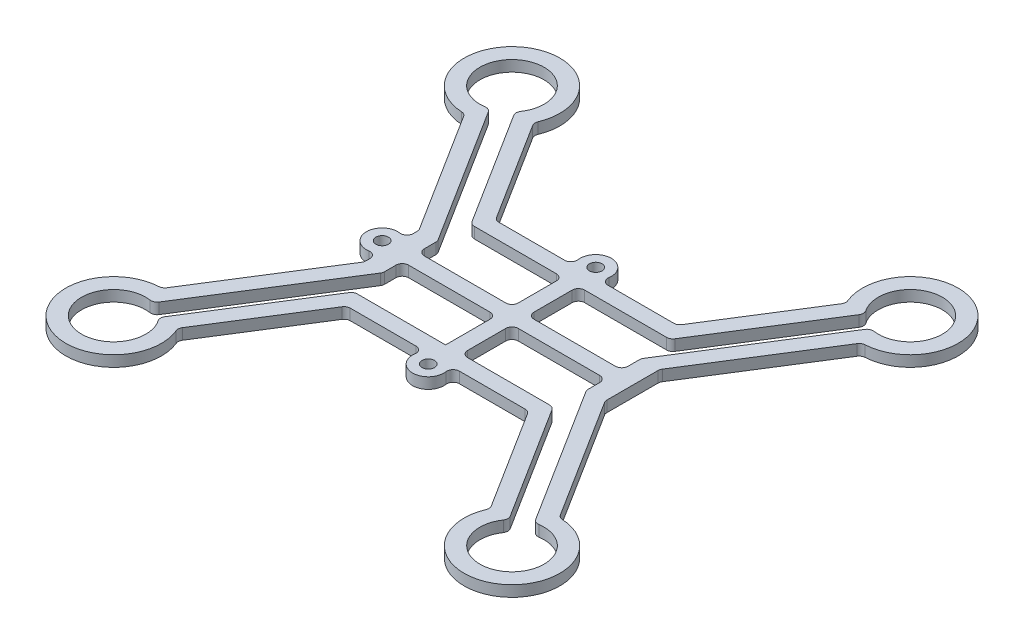
from build123d import *

# Parameters (mm, degrees)
SKETCH1_R           = 5.125
BOSS_EXTRUDE1_DEPTH = 1.75
CUT_EXTRUDE2_REACH  = 3.75
FILLET1_R           = 1
SKETCH4_R           = 2.5
SKETCH4_R_2         = 1
BOSS_EXTRUDE2_DEPTH = 1.75
FILLET2_R           = 1


with BuildPart() as part:
    # Sketch1 → Boss-Extrude1 (new body)
    with BuildSketch(Plane(origin=(0, 0, 0), x_dir=(1, 0, 0), z_dir=(0, 1, 0))):
        with BuildLine():
            Line((19.25, -4.372796114), (19.25, 4.372796114))
            Line((19.25, 4.372796114), (31.727014355, 24.170367928))
            ThreePointArc((31.727014355, 24.170367928), (35.898606592, 38.291735223), (24.95898291, 28.435781196))
            Line((24.95898291, 28.435781196), (14.52188958, 11.875))
            Line((14.52188958, 11.875), (-14.52188958, 11.875))
            Line((-14.52188958, 11.875), (-24.95898291, 28.435781196))
            ThreePointArc((-24.95898291, 28.435781196), (-35.898606592, 38.291735223), (-31.727014355, 24.170367928))
            Line((-31.727014355, 24.170367928), (-19.25, 4.372796114))
            Line((-19.25, 4.372796114), (-19.25, -4.372796114))
            Line((-19.25, -4.372796114), (-31.727014355, -24.170367928))
            ThreePointArc((-31.727014355, -24.170367928), (-35.898606592, -38.291735223), (-24.95898291, -28.435781196))
            Line((-24.95898291, -28.435781196), (-14.52188958, -11.875))
            Line((-14.52188958, -11.875), (14.52188958, -11.875))
            Line((14.52188958, -11.875), (24.95898291, -28.435781196))
            ThreePointArc((24.95898291, -28.435781196), (35.898606592, -38.291735223), (31.727014355, -24.170367928))
            Line((31.727014355, -24.170367928), (19.25, -4.372796114))
        make_face()
        with Locations((-31.819805153, 31.819805153)):
            Circle(SKETCH1_R, mode=Mode.SUBTRACT)
        with Locations((31.819805153, 31.819805153)):
            Circle(SKETCH1_R, mode=Mode.SUBTRACT)
        with Locations((-31.819805153, -31.819805153)):
            Circle(SKETCH1_R, mode=Mode.SUBTRACT)
        with Locations((31.819805153, -31.819805153)):
            Circle(SKETCH1_R, mode=Mode.SUBTRACT)
    extrude(amount=BOSS_EXTRUDE1_DEPTH)

    # Sketch2 → Cut-Extrude2 (cut, up to next)
    with BuildSketch(Plane(origin=(0, 1.75, 0), x_dir=(1, 0, 0), z_dir=(0, 1, 0)), mode=Mode.PRIVATE) as cut_extrude2_sk1:
        with BuildLine():
            ThreePointArc((-27.955034886, 28.453921053), (-29.087274778, 27.484035009), (-30.450746481, 26.88104991))
            Line((-30.450746481, 26.88104991), (-16.265380297, 4.372796114))
            Line((-16.265380297, 4.372796114), (-16.265380297, 1.2625))
            Line((-16.265380297, 1.2625), (-1.2625, 1.2625))
            Line((-1.2625, 1.2625), (-1.2625, 9.35))
            Line((-1.2625, 9.35), (-15.915179722, 9.35))
            Line((-15.915179722, 9.35), (-27.955034886, 28.453921053))
        make_face()
    cut_extrude2_tool1 = extrude(cut_extrude2_sk1.sketch, amount=-CUT_EXTRUDE2_REACH, mode=Mode.PRIVATE) & part.part
    add(cut_extrude2_tool1.solids().sort_by_distance((-22.27259, 1.75, -18.689269))[0], mode=Mode.SUBTRACT)
    # Sketch2 → Cut-Extrude2 (cut, up to next)
    with BuildSketch(Plane(origin=(0, 1.75, 0), x_dir=(1, 0, 0), z_dir=(0, 1, 0)), mode=Mode.PRIVATE) as cut_extrude2_sk2:
        with BuildLine():
            Line((-16.265380297, -1.2625), (-16.265380297, -4.372796114))
            Line((-16.265380297, -4.372796114), (-30.450746481, -26.88104991))
            ThreePointArc((-30.450746481, -26.88104991), (-29.087274778, -27.484035009), (-27.955034886, -28.453921053))
            Line((-27.955034886, -28.453921053), (-15.915179722, -9.35))
            Line((-15.915179722, -9.35), (-1.2625, -9.35))
            Line((-1.2625, -9.35), (-1.2625, -1.2625))
            Line((-1.2625, -1.2625), (-16.265380297, -1.2625))
        make_face()
    cut_extrude2_tool2 = extrude(cut_extrude2_sk2.sketch, amount=-CUT_EXTRUDE2_REACH, mode=Mode.PRIVATE) & part.part
    add(cut_extrude2_tool2.solids().sort_by_distance((-15.866466, 1.75, 2.817648))[0], mode=Mode.SUBTRACT)
    # Sketch2 → Cut-Extrude2 (cut, up to next)
    with BuildSketch(Plane(origin=(0, 1.75, 0), x_dir=(1, 0, 0), z_dir=(0, 1, 0)), mode=Mode.PRIVATE) as cut_extrude2_sk3:
        with BuildLine():
            Line((15.915179722, 9.35), (1.2625, 9.35))
            Line((1.2625, 9.35), (1.2625, 1.2625))
            Line((1.2625, 1.2625), (16.265380297, 1.2625))
            Line((16.265380297, 1.2625), (16.265380297, 4.372796114))
            Line((16.265380297, 4.372796114), (30.450746481, 26.88104991))
            ThreePointArc((30.450746481, 26.88104991), (29.087274778, 27.484035009), (27.955034886, 28.453921053))
            Line((27.955034886, 28.453921053), (15.915179722, 9.35))
        make_face()
    cut_extrude2_tool3 = extrude(cut_extrude2_sk3.sketch, amount=-CUT_EXTRUDE2_REACH, mode=Mode.PRIVATE) & part.part
    add(cut_extrude2_tool3.solids().sort_by_distance((22.27259, 1.75, -18.689269))[0], mode=Mode.SUBTRACT)
    # Sketch2 → Cut-Extrude2 (cut, up to next)
    with BuildSketch(Plane(origin=(0, 1.75, 0), x_dir=(1, 0, 0), z_dir=(0, 1, 0)), mode=Mode.PRIVATE) as cut_extrude2_sk4:
        with BuildLine():
            Line((1.2625, -1.2625), (1.2625, -9.35))
            Line((1.2625, -9.35), (15.915179722, -9.35))
            Line((15.915179722, -9.35), (27.955034886, -28.453921053))
            ThreePointArc((27.955034886, -28.453921053), (29.087274778, -27.484035009), (30.450746481, -26.88104991))
            Line((30.450746481, -26.88104991), (16.265380297, -4.372796114))
            Line((16.265380297, -4.372796114), (16.265380297, -1.2625))
            Line((16.265380297, -1.2625), (1.2625, -1.2625))
        make_face()
    cut_extrude2_tool4 = extrude(cut_extrude2_sk4.sketch, amount=-CUT_EXTRUDE2_REACH, mode=Mode.PRIVATE) & part.part
    add(cut_extrude2_tool4.solids().sort_by_distance((28.874583, 1.75, 27.146552))[0], mode=Mode.SUBTRACT)

    # Fillet1
    fillet1_edges = [part.edges().sort_by_distance(p)[0] for p in [
        (16.265380297, 0.875, -1.2625),
        (1.2625, 0.875, -1.2625),
        (1.2625, 0.875, -9.35),
        (15.915179722, 0.875, -9.35),
        (27.955034886, 0.875, -28.453921053),
        (30.450746481, 0.875, -26.88104991),
        (16.265380297, 0.875, -4.372796114),
        (-31.727014355, 0.875, 24.170367928),
        (-19.25, 0.875, 4.372796114),
        (-14.52188958, 0.875, 11.875),
        (-24.95898291, 0.875, 28.435781196),
        (1.2625, 0.875, 1.2625),
        (16.265380297, 0.875, 1.2625),
        (16.265380297, 0.875, 4.372796114),
        (30.450746481, 0.875, 26.88104991),
        (27.955034886, 0.875, 28.453921053),
        (15.915179722, 0.875, 9.35),
        (1.2625, 0.875, 9.35),
        (-16.265380297, 0.875, 1.2625),
        (-1.2625, 0.875, 1.2625),
        (-15.915179722, 0.875, 9.35),
        (-27.955034886, 0.875, 28.453921053),
        (-30.450746481, 0.875, 26.88104991),
        (-16.265380297, 0.875, 4.372796114),
        (-31.727014355, 0.875, -24.170367928),
        (-19.25, 0.875, -4.372796114),
        (-14.52188958, 0.875, -11.875),
        (-24.95898291, 0.875, -28.435781196),
        (31.727014355, 0.875, 24.170367928),
        (19.25, 0.875, 4.372796114),
        (14.52188958, 0.875, 11.875),
        (24.95898291, 0.875, 28.435781196),
        (24.95898291, 0.875, -28.435781196),
        (14.52188958, 0.875, -11.875),
        (19.25, 0.875, -4.372796114),
        (31.727014355, 0.875, -24.170367928),
        (-1.2625, 0.875, -1.2625),
        (-16.265380297, 0.875, -1.2625),
        (-16.265380297, 0.875, -4.372796114),
        (-30.450746481, 0.875, -26.88104991),
        (-27.955034886, 0.875, -28.453921053),
        (-15.915179722, 0.875, -9.35),
        (-1.2625, 0.875, -9.35),
    ]]
    fillet(fillet1_edges, radius=FILLET1_R)

    # Sketch4 → Boss-Extrude2 (add)
    with BuildSketch(Plane.XZ):
        with Locations((-20.75, 0)):
            Circle(SKETCH4_R)
        with Locations((-20.75, 0)):
            Circle(SKETCH4_R_2, mode=Mode.SUBTRACT)
        with Locations((0, -13.375)):
            Circle(SKETCH4_R)
        Polygon((0.866025404, -11.875), (-0.866025404, -11.875), (-1.732050808, -13.375), (-0.866025404, -14.875), (0.866025404, -14.875), (1.732050808, -13.375), align=None, mode=Mode.SUBTRACT)
        Polygon((1.732050808, -13.375), (0.866025404, -11.875), (-0.866025404, -11.875), (-1.732050808, -13.375), (-0.866025404, -14.875), (0.866025404, -14.875), align=None)
        with Locations((0, -13.375)):
            Circle(SKETCH4_R_2, mode=Mode.SUBTRACT)
        with Locations((0, 13.375)):
            Circle(SKETCH4_R)
        with Locations((0, 13.375)):
            Circle(SKETCH4_R_2, mode=Mode.SUBTRACT)
    extrude(amount=-BOSS_EXTRUDE2_DEPTH)

    # Fillet2
    fillet2_edges = [part.edges().sort_by_distance(p)[0] for p in [
        (-19.25, 0.875, -2),
        (-19.25, 0.875, 2),
        (-2, 0.875, -11.875),
        (2, 0.875, -11.875),
        (-2, 0.875, 11.875),
        (2, 0.875, 11.875),
    ]]
    fillet(fillet2_edges, radius=FILLET2_R)


solid = part.part
